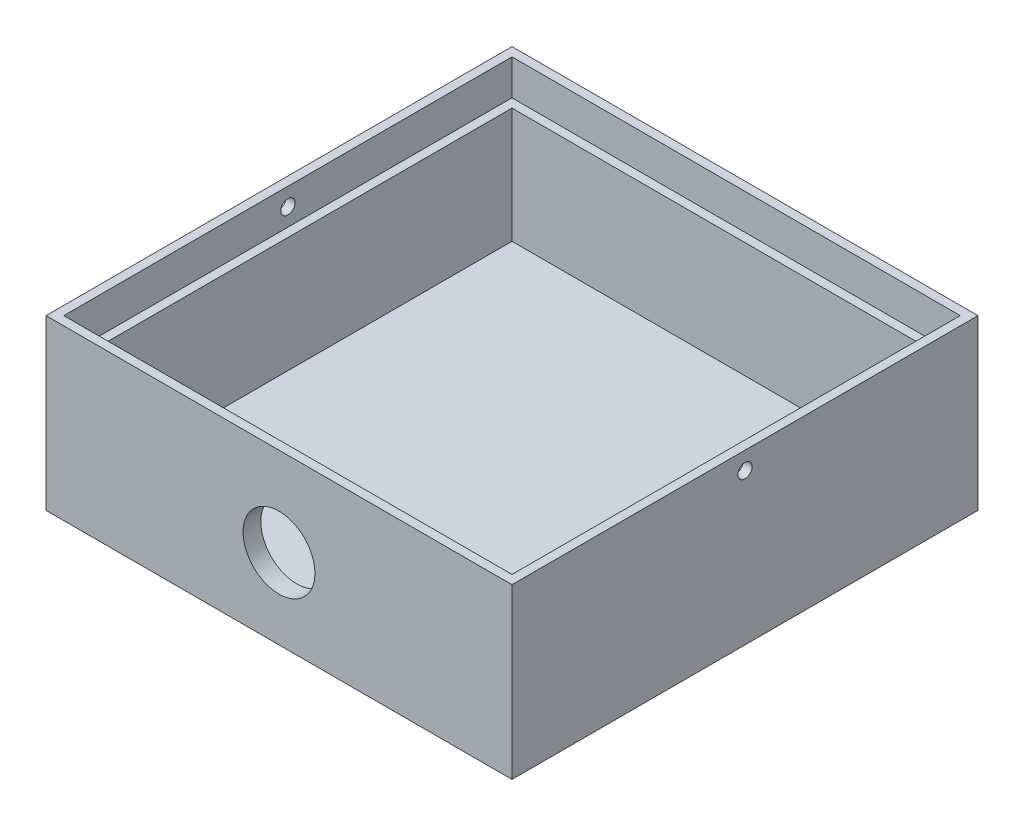
from build123d import *

# Parameters (mm, degrees)
SKETCH1_W           = 105
SKETCH1_H           = 105
BOSS_EXTRUDE1_DEPTH = 38
SKETCH2_W           = 97
SKETCH2_H           = 97
CUT_EXTRUDE1_DEPTH  = 34
SKETCH3_W           = 101
SKETCH3_H           = 101
CUT_EXTRUDE2_DEPTH  = 8
SKETCH5_R           = 1.6
CUT_EXTRUDE3_DEPTH  = 106
SKETCH6_R           = 2.75
BOSS_EXTRUDE2_DEPTH = 3
FILLET1_R           = 4
CUT_EXTRUDE4_REACH  = 6
SKETCH7_R           = 8.1
CUT_EXTRUDE5_DEPTH  = 1


with BuildPart() as part:
    # Sketch1 → Boss-Extrude1 (new body)
    with BuildSketch(Plane(origin=(0, 0, 0), x_dir=(1, 0, 0), z_dir=(0, 1, 0))):
        Rectangle(SKETCH1_W, SKETCH1_H)
    extrude(amount=BOSS_EXTRUDE1_DEPTH)

    # Sketch2 → Cut-Extrude1 (cut)
    with BuildSketch(Plane(origin=(0, 38, 0), x_dir=(1, 0, 0), z_dir=(0, 1, 0))):
        Rectangle(SKETCH2_W, SKETCH2_H)
    extrude(amount=-CUT_EXTRUDE1_DEPTH, mode=Mode.SUBTRACT)

    # Sketch3 → Cut-Extrude2 (cut)
    with BuildSketch(Plane(origin=(0, 38, 0), x_dir=(1, 0, 0), z_dir=(0, 1, 0))):
        Rectangle(SKETCH3_W, SKETCH3_H)
    extrude(amount=-CUT_EXTRUDE2_DEPTH, mode=Mode.SUBTRACT)

    # Sketch5 → Cut-Extrude3 (cut, through all)
    with BuildSketch(Plane(origin=(52.5, 0, 0), x_dir=(0, 0, -1), z_dir=(1, 0, 0))):
        with Locations((0, 34)):
            Circle(SKETCH5_R)
    extrude(amount=-CUT_EXTRUDE3_DEPTH, mode=Mode.SUBTRACT)

    # Sketch6 → Boss-Extrude2 (add)
    with BuildSketch(Plane(origin=(0, 0, -52.5), x_dir=(-1, 0, 0), z_dir=(0, 0, -1))):
        with BuildLine():
            Line((-12, 0), (12, 0))
            Line((12, 0), (12, -5))
            Line((12, -5), (12, -17))
            ThreePointArc((12, -17), (0, -29), (-12, -17))
            Line((-12, -17), (-12, -5))
            Line((-12, -5), (-12, 0))
        make_face()
        with Locations((0, -17)):
            Circle(SKETCH6_R, mode=Mode.SUBTRACT)
    extrude(amount=-BOSS_EXTRUDE2_DEPTH)

    # Fillet1
    fillet1_edges = [part.edges().sort_by_distance(p)[0] for p in [
        (0, 0, -49.5),
        (12, 0, -51),
        (-12, 0, -51),
    ]]
    fillet(fillet1_edges, radius=FILLET1_R)

    # Sketch7 → Cut-Extrude4 (cut, up to next)
    with BuildSketch(Plane(origin=(0, 0, 48.5), x_dir=(-1, 0, 0), z_dir=(0, 0, -1)), mode=Mode.PRIVATE) as cut_extrude4_sk1:
        with Locations((0, 18)):
            Circle(SKETCH7_R)
    cut_extrude4_tool1 = extrude(cut_extrude4_sk1.sketch, amount=-CUT_EXTRUDE4_REACH, mode=Mode.PRIVATE) & part.part
    add(cut_extrude4_tool1.solids().sort_by_distance((0, 18, 48.5))[0], mode=Mode.SUBTRACT)

    # Sketch10 → Cut-Extrude5 (cut)
    with BuildSketch(Plane.XZ):
        with BuildLine():
            Line((5, -10), (0, -10))
            ThreePointArc((0, -10), (-5, -5), (0, 0))
            ThreePointArc((0, 0), (-5, 5), (0, 10))
            Line((0, 10), (5, 10))
            Line((5, 10), (5, -10))
        make_face()
        with BuildLine():
            Line((0, -7), (2, -7))
            Line((2, -7), (2, -3))
            Line((2, -3), (0, -3))
            ThreePointArc((0, -3), (-2, -5), (0, -7))
        make_face(mode=Mode.SUBTRACT)
        with BuildLine():
            Line((0, 3), (2, 3))
            Line((2, 3), (2, 7))
            Line((2, 7), (0, 7))
            ThreePointArc((0, 7), (-2, 5), (0, 3))
        make_face(mode=Mode.SUBTRACT)
    extrude(amount=-CUT_EXTRUDE5_DEPTH, mode=Mode.SUBTRACT)


solid = part.part
